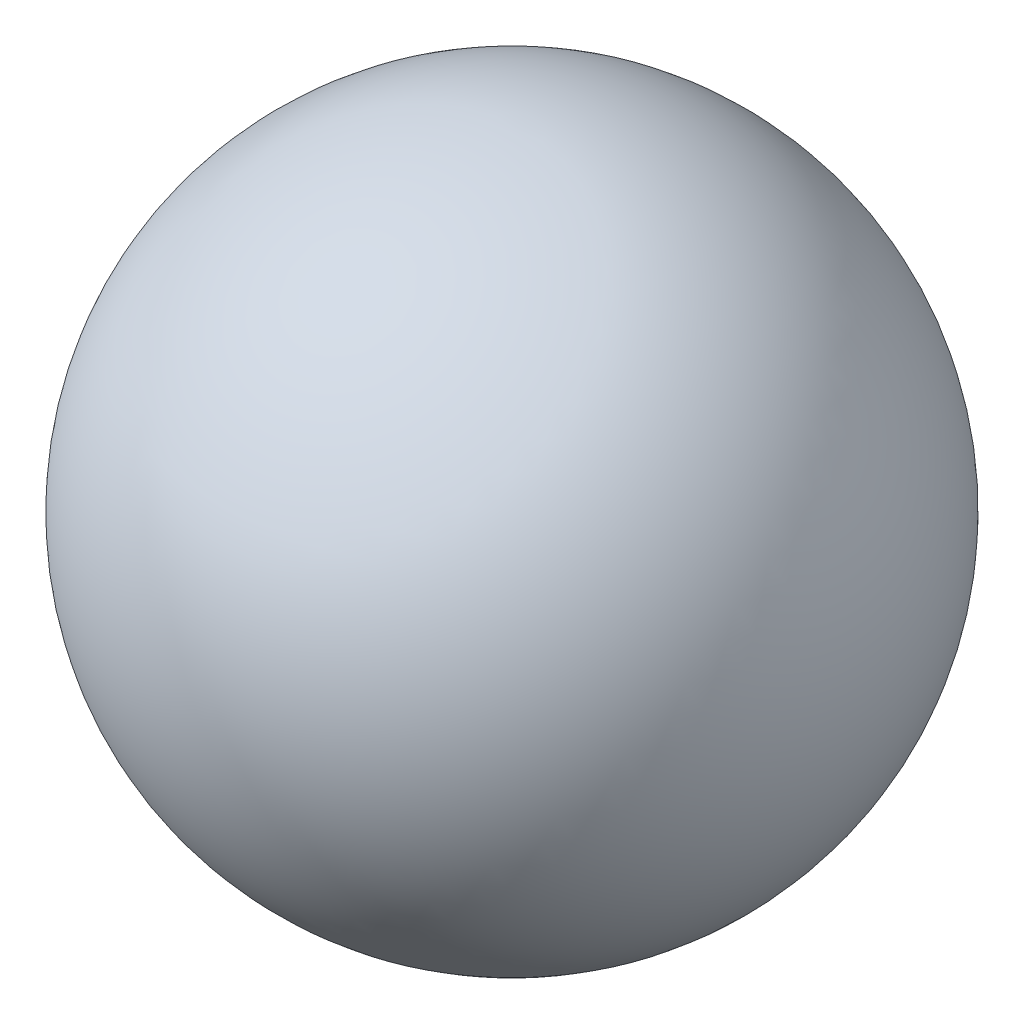
from build123d import *

# Parameters (mm, degrees)
SKETCH2_R          = 6
CUT_EXTRUDE1_DEPTH = 12


with BuildPart() as part:
    # Sketch1 → Revolve1 (revolve)
    with BuildSketch(Plane.XY):
        with BuildLine():
            Line((0, -26), (0, 30))
            ThreePointArc((0, 30), (28.982753492, 7.745966692), (14.966629547, -26))
            Line((14.966629547, -26), (0, -26))
        make_face()
    revolve(axis=Axis((0, -26, 0), (0, 1, 0)))

    # Sketch2 → Cut-Extrude1 (cut)
    with BuildSketch(Plane.XZ.offset(26)):
        Circle(SKETCH2_R)
    extrude(amount=-CUT_EXTRUDE1_DEPTH, mode=Mode.SUBTRACT)


solid = part.part
